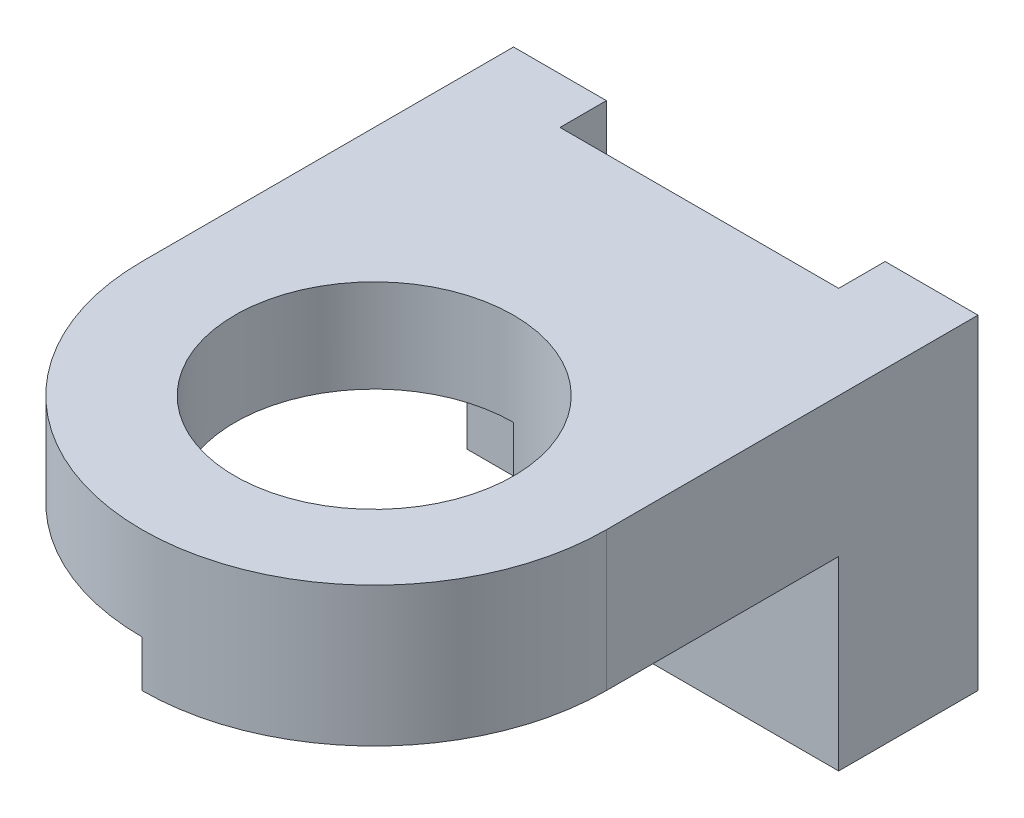
from build123d import *

# Parameters (mm, degrees)
SKETCH1_W           = 100
SKETCH1_H           = 40
BOSS_EXTRUDE1_DEPTH = 30
SKETCH2_W           = 50
SKETCH2_H           = 20
CUT_EXTRUDE1_DEPTH  = 30
SKETCH3_W           = 60
SKETCH3_H           = 10
CUT_EXTRUDE3_DEPTH  = 110
BOSS_EXTRUDE2_DEPTH = 10
SKETCH5_W           = 100
SKETCH5_H           = 10
BOSS_EXTRUDE3_DEPTH = 10
CUT_EXTRUDE4_DEPTH  = 45
SKETCH7_W           = 100
SKETCH7_H           = 130
BOSS_EXTRUDE4_DEPTH = 20
SKETCH8_R           = 30
CUT_EXTRUDE5_DEPTH  = 20
CUT_EXTRUDE6_DEPTH  = 20
BOSS_EXTRUDE5_DEPTH = 10
SKETCH12_W          = 60
SKETCH12_H          = 10
CUT_EXTRUDE9_DEPTH  = 56


with BuildPart() as part:
    # Sketch1 → Boss-Extrude1 (new body)
    with BuildSketch(Plane.XY):
        with Locations((50, 20)):
            Rectangle(SKETCH1_W, SKETCH1_H)
    extrude(amount=BOSS_EXTRUDE1_DEPTH)

    # Sketch2 → Cut-Extrude1 (cut)
    with BuildSketch(Plane.XY.offset(30)):
        with Locations((25, 10)):
            Rectangle(SKETCH2_W, SKETCH2_H)
    extrude(amount=-CUT_EXTRUDE1_DEPTH, mode=Mode.SUBTRACT)

    # Sketch3 → Cut-Extrude3 (cut)
    with BuildSketch(Plane(origin=(0, 40, 0), x_dir=(1, 0, 0), z_dir=(0, 1, 0))):
        with Locations((50, -5)):
            Rectangle(SKETCH3_W, SKETCH3_H)
    extrude(amount=-CUT_EXTRUDE3_DEPTH, mode=Mode.SUBTRACT)

    # Sketch4 → Boss-Extrude2 (add)
    with BuildSketch(Plane(origin=(0, 40, 0), x_dir=(1, 0, 0), z_dir=(0, 1, 0))):
        Polygon((100, 0), (100, -30), (0, -30), (0, 0), (20, 0), (20, -10), (80, -10), (80, 0), align=None)
    extrude(amount=BOSS_EXTRUDE2_DEPTH)

    # Sketch5 → Boss-Extrude3 (add)
    with BuildSketch(Plane.XY.offset(30)):
        with Locations((50, 45)):
            Rectangle(SKETCH5_W, SKETCH5_H)
    extrude(amount=BOSS_EXTRUDE3_DEPTH)

    # Sketch6 → Cut-Extrude4 (cut)
    with BuildSketch(Plane(origin=(0, 50, 0), x_dir=(1, 0, 0), z_dir=(0, 1, 0))):
        Polygon((0, -10), (30, -40), (0, -40), align=None)
    extrude(amount=-CUT_EXTRUDE4_DEPTH, mode=Mode.SUBTRACT)

    # Sketch7 → Boss-Extrude4 (add)
    with BuildSketch(Plane(origin=(0, 50, 0), x_dir=(1, 0, 0), z_dir=(0, 1, 0))):
        with Locations((50, -65)):
            Rectangle(SKETCH7_W, SKETCH7_H)
    extrude(amount=BOSS_EXTRUDE4_DEPTH)

    # Sketch8 → Cut-Extrude5 (cut)
    with BuildSketch(Plane.XZ.offset(-50)):
        with Locations(Location((50, 80, 0), (0, 0, 270))):
            Circle(SKETCH8_R)
    extrude(amount=-CUT_EXTRUDE5_DEPTH, mode=Mode.SUBTRACT)

    # Sketch9 → Cut-Extrude6 (cut)
    with BuildSketch(Plane(origin=(0, 50, 0), x_dir=(-1, 0, 0), z_dir=(0, -1, 0))):
        with BuildLine():
            Line((0, -130), (0, -80))
            ThreePointArc((0, -80), (-14.644660941, -115.355339059), (-50, -130))
            Line((-50, -130), (0, -130))
        make_face()
        with BuildLine():
            Line((-100, -130), (-50, -130))
            ThreePointArc((-50, -130), (-85.355339059, -115.355339059), (-100, -80))
            Line((-100, -80), (-100, -130))
        make_face()
    extrude(amount=-CUT_EXTRUDE6_DEPTH, mode=Mode.SUBTRACT)

    # Sketch10 → Boss-Extrude5 (add)
    with BuildSketch(Plane(origin=(0, 50, 0), x_dir=(-1, 0, 0), z_dir=(0, -1, 0))):
        with BuildLine():
            Line((-50, -110), (-50, -130))
            ThreePointArc((-50, -130), (-85.355339059, -115.355339059), (-100, -80))
            Line((-100, -80), (-100, -40))
            Line((-100, -40), (-50, -40))
            Line((-50, -40), (-50, -50))
            ThreePointArc((-50, -50), (-80, -80), (-50, -110))
        make_face()
    extrude(amount=BOSS_EXTRUDE5_DEPTH)

    # Sketch12 → Cut-Extrude9 (cut)
    with BuildSketch(Plane.XZ.offset(-50)):
        with Locations((50, 5)):
            Rectangle(SKETCH12_W, SKETCH12_H)
    extrude(amount=-CUT_EXTRUDE9_DEPTH, mode=Mode.SUBTRACT)


solid = part.part
